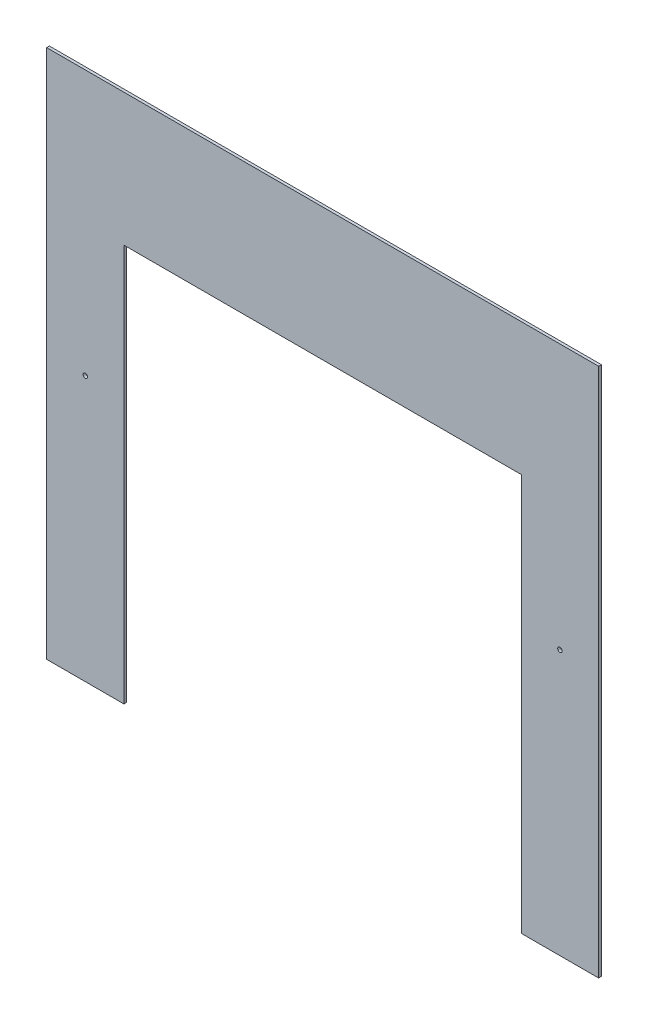
from build123d import *

# Parameters (mm, degrees)
BOSS_EXTRUDE1_DEPTH = 3.175
SKETCH2_R           = 2.5796875
CUT_EXTRUDE1_DEPTH  = 4.175


with BuildPart() as part:
    # Sketch1 → Boss-Extrude1 (new body)
    with BuildSketch(Plane.XY):
        Polygon((-441.3957506, 526.537652812), (193.6042494, 526.537652812), (193.6042494, -83.062347188), (104.7042494, -83.062347188), (104.7042494, 374.137652812), (-352.4957506, 374.137652812), (-352.4957506, -83.062347188), (-441.3957506, -83.062347188), (-441.3957506, 36.485330073), align=None)
    extrude(amount=BOSS_EXTRUDE1_DEPTH)

    # Sketch2 → Cut-Extrude1 (cut, through all)
    with BuildSketch(Plane.XY.offset(3.175)):
        with Locations((-396.9457506, 221.737652812)):
            Circle(SKETCH2_R)
        with Locations((149.1542494, 221.737652812)):
            Circle(SKETCH2_R)
    extrude(amount=-CUT_EXTRUDE1_DEPTH, mode=Mode.SUBTRACT)


solid = part.part
